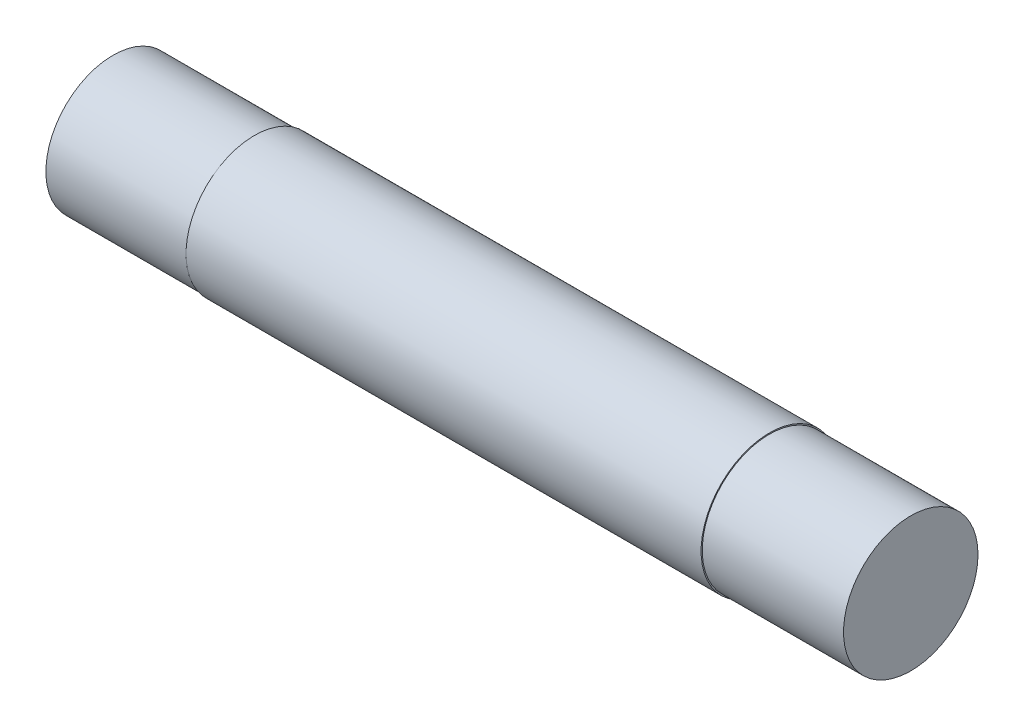
from build123d import *

# Parameters (mm, degrees)
SKETCH1_R               = 3.81
BOSS_EXTRUDE1_DEPTH     = 22.225
SKETCH2_R               = 6.2865
SKETCH2_R_2             = 3.7465
CUT_EXTRUDE_THIN3_DEPTH = 7.874


with BuildPart() as part:
    # Sketch1 → Boss-Extrude1 (new body, symmetric)
    with BuildSketch(Plane(origin=(0, 0, 0), x_dir=(0, 0, -1), z_dir=(1, 0, 0))):
        Circle(SKETCH1_R)
    extrude(amount=BOSS_EXTRUDE1_DEPTH, both=True)

    # Sketch2 → Cut-Extrude-Thin3 (cut)
    with BuildSketch(Plane(origin=(22.225, 0, 0), x_dir=(0, 0, -1), z_dir=(1, 0, 0))):
        Circle(SKETCH2_R)
        Circle(SKETCH2_R_2, mode=Mode.SUBTRACT)
    cut_extrude_thin3 = extrude(amount=-CUT_EXTRUDE_THIN3_DEPTH, mode=Mode.SUBTRACT)

    # Mirror1: Cut-Extrude-Thin3 across plane
    add(cut_extrude_thin3.mirror(Plane(origin=(0, 0, 0), x_dir=(0, 0, 1), z_dir=(1, 0, 0))), mode=Mode.SUBTRACT)


solid = part.part
